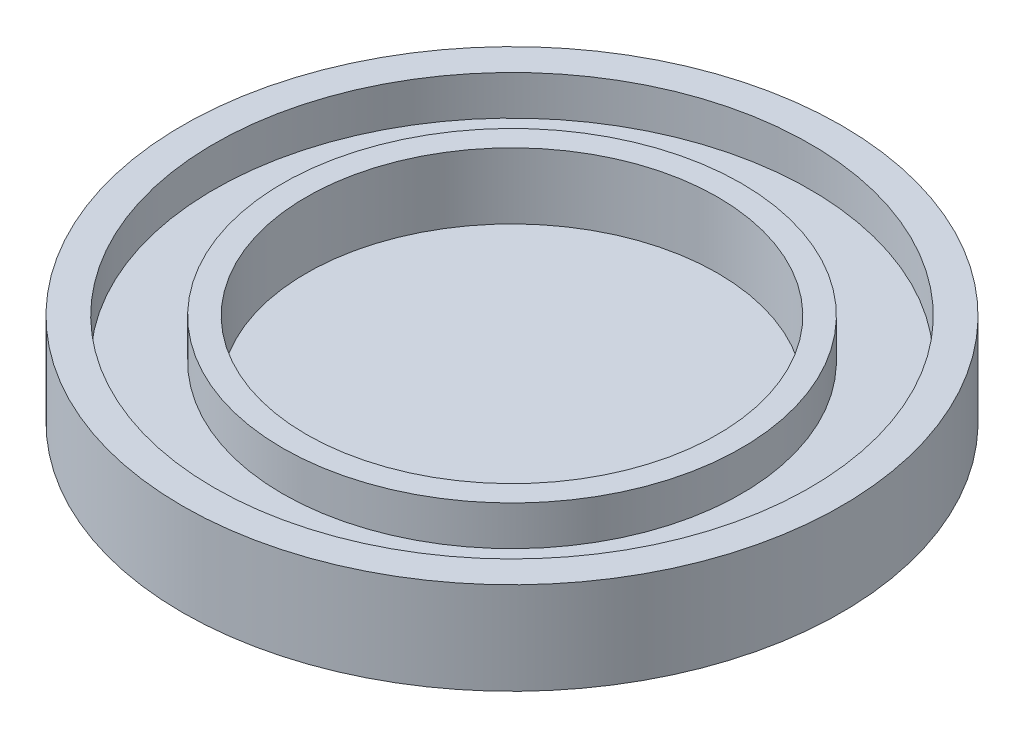
from build123d import *

# Parameters (mm, degrees)
ESQUISSE2_R             = 25
BOSS_EXTRU_1_DEPTH      = 7
ESQUISSE3_R             = 15.6
ENL_V_MAT_EXTRU_1_DEPTH = 5
ESQUISSE5_R             = 22.6
ESQUISSE5_R_2           = 17.4
ENL_V_MAT_EXTRU_2_DEPTH = 3


with BuildPart() as part:
    # Esquisse2 → Boss.-Extru.1 (new body)
    with BuildSketch(Plane(origin=(0, 0, 0), x_dir=(1, 0, 0), z_dir=(0, 1, 0))):
        Circle(ESQUISSE2_R)
    extrude(amount=BOSS_EXTRU_1_DEPTH)

    # Esquisse3 → Enlèv. mat.-Extru.1 (cut)
    with BuildSketch(Plane(origin=(0, 7, 0), x_dir=(1, 0, 0), z_dir=(0, 1, 0))):
        Circle(ESQUISSE3_R)
    extrude(amount=-ENL_V_MAT_EXTRU_1_DEPTH, mode=Mode.SUBTRACT)

    # Esquisse5 → Enlèv. mat.-Extru.2 (cut)
    with BuildSketch(Plane(origin=(0, 7, 0), x_dir=(1, 0, 0), z_dir=(0, 1, 0))):
        Circle(ESQUISSE5_R)
        Circle(ESQUISSE5_R_2, mode=Mode.SUBTRACT)
    extrude(amount=-ENL_V_MAT_EXTRU_2_DEPTH, mode=Mode.SUBTRACT)


solid = part.part
